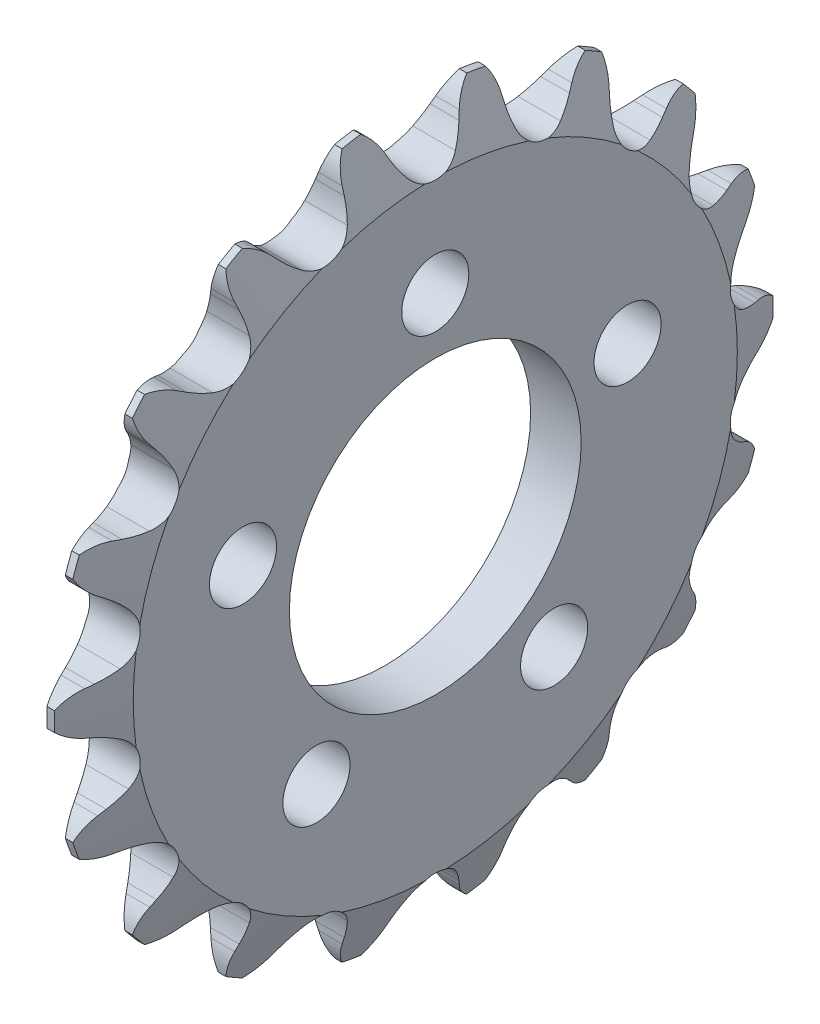
from build123d import *

# Parameters (mm, degrees)
CUT_EXTRUDE1_DEPTH = 29.137382372
CIRPATTERN1_COUNT  = 18
SKETCH4_R          = 8.0645
SKETCH4_R_2        = 1.8542
CUT_EXTRUDE2_DEPTH = 29.08854933


with BuildPart() as part:
    # Sketch2 → Revolve1 (revolve)
    with BuildSketch(Plane.XY):
        Polygon((-0.206375, 19.871596284), (0.206375, 19.871596284), (1.397, 16.696596284), (1.397, 0), (-1.397, 0), (-1.397, 16.696596284), align=None)
    revolve(axis=Axis((-1.397, 0, 0), (1, 0, 0)))

    # Sketch3 → Cut-Extrude1 (cut, symmetric)
    with BuildSketch(Plane(origin=(0, 0, 0), x_dir=(0, 0, -1), z_dir=(1, 0, 0))):
        with BuildLine():
            Line((-2.066224101, 18.559583724), (-1.908645709, 18.196215131))
            ThreePointArc((-1.908645709, 18.196215131), (-1.651424634, 17.695000021), (-1.331431851, 17.231336472))
            ThreePointArc((-1.331431851, 17.231336472), (0, 16.586741284), (1.331431851, 17.231336472))
            ThreePointArc((1.331431851, 17.231336472), (1.651424634, 17.695000021), (1.908645709, 18.196215131))
            Line((1.908645709, 18.196215131), (2.066224101, 18.559583724))
            ThreePointArc((2.066224101, 18.559583724), (2.655633711, 19.416846104), (3.524580563, 19.988889671))
            ThreePointArc((3.524580563, 19.988889671), (0, 20.297250514), (-3.524580563, 19.988889671))
            ThreePointArc((-3.524580563, 19.988889671), (-2.655633711, 19.416846104), (-2.066224101, 18.559583724))
        make_face()
    cut_extrude1 = extrude(amount=CUT_EXTRUDE1_DEPTH, both=True, mode=Mode.SUBTRACT)

    # CirPattern1: Cut-Extrude1 ×18 about axis
    cirpattern1_axis = Axis((-88.99, 0, 0), (1, 0, 0))
    for i in range(1, CIRPATTERN1_COUNT):
        add(cut_extrude1.rotate(cirpattern1_axis, i * 360 / CIRPATTERN1_COUNT), mode=Mode.SUBTRACT)

    # Sketch4 → Cut-Extrude2 (cut, through all)
    with BuildSketch(Plane(origin=(1.397, 0, 0), x_dir=(0, 0, -1), z_dir=(1, 0, 0))):
        Circle(SKETCH4_R)
        with Locations((0, 11.176)):
            Circle(SKETCH4_R_2)
        with Locations((10.629007626, 3.453573929)):
            Circle(SKETCH4_R_2)
        with Locations((6.56908798, -9.041573929)):
            Circle(SKETCH4_R_2)
        with Locations((-6.56908798, -9.041573929)):
            Circle(SKETCH4_R_2)
        with Locations((-10.629007626, 3.453573929)):
            Circle(SKETCH4_R_2)
    extrude(amount=-CUT_EXTRUDE2_DEPTH, mode=Mode.SUBTRACT)


solid = part.part
